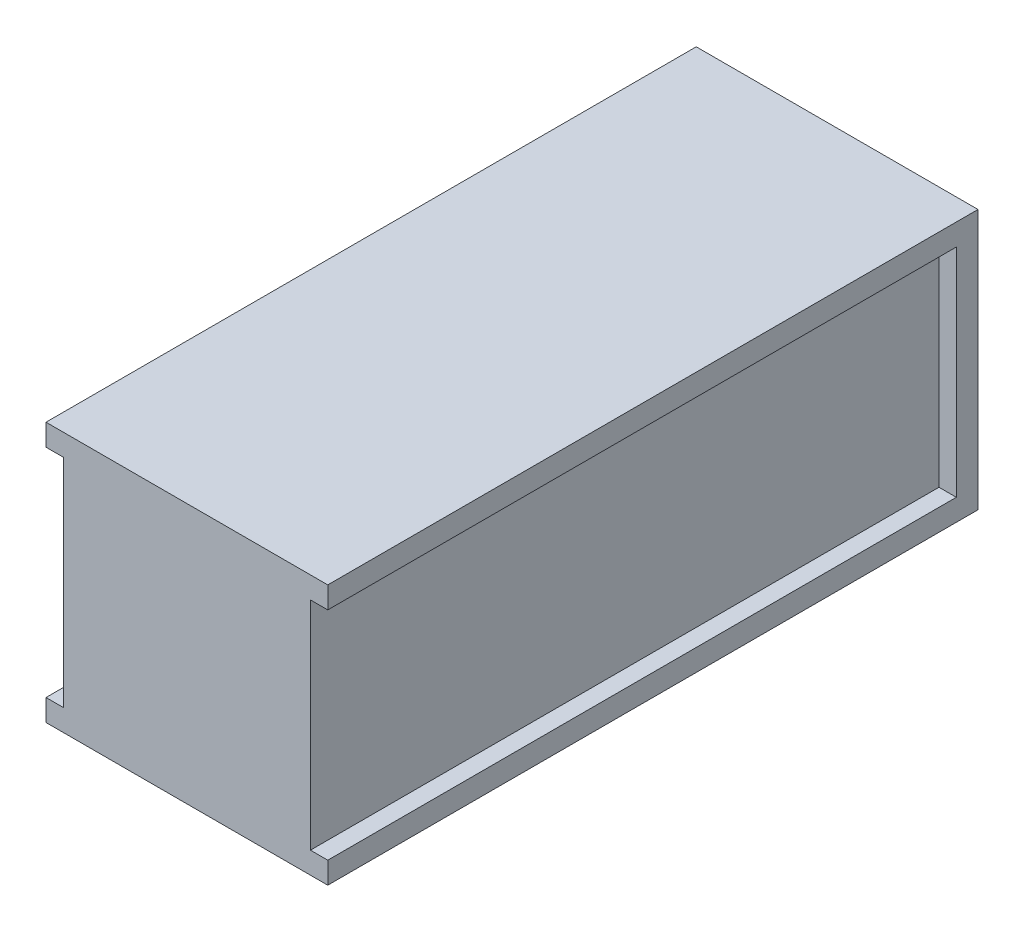
from build123d import *

# Parameters (mm, degrees)
ESQUISSE1_W             = 65
ESQUISSE1_H             = 150
BOSS_EXTRU_1_DEPTH      = 60
ESQUISSE2_W             = 145
ESQUISSE2_H             = 50
ENL_V_MAT_EXTRU_1_DEPTH = 4


with BuildPart() as part:
    # Esquisse1 → Boss.-Extru.1 (new body)
    with BuildSketch(Plane(origin=(0, 0, 0), x_dir=(1, 0, 0), z_dir=(0, 1, 0))):
        Rectangle(ESQUISSE1_W, ESQUISSE1_H)
    extrude(amount=BOSS_EXTRU_1_DEPTH)

    # Esquisse2 → Enlèv. mat.-Extru.1 (cut)
    with BuildSketch(Plane.ZY.offset(32.5)):
        with Locations((2.5, 30)):
            Rectangle(ESQUISSE2_W, ESQUISSE2_H)
    enl_v_mat_extru_1 = extrude(amount=-ENL_V_MAT_EXTRU_1_DEPTH, mode=Mode.SUBTRACT)

    # Symétrie1: Enlèv. mat.-Extru.1 across plane
    add(enl_v_mat_extru_1.mirror(Plane(origin=(0, 0, 0), x_dir=(0, 0, 1), z_dir=(1, 0, 0))), mode=Mode.SUBTRACT)


solid = part.part
